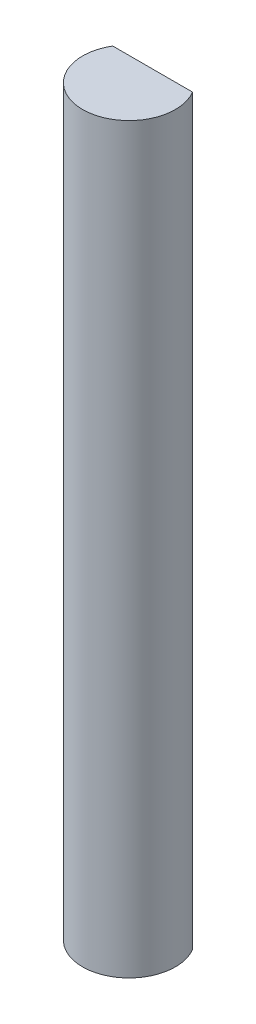
from build123d import *

# Parameters (mm, degrees)
BOSS_EXTRUDE1_DEPTH = 50.8


with BuildPart() as part:
    # Sketch1 → Boss-Extrude1 (new body)
    with BuildSketch(Plane(origin=(0, 0, 0), x_dir=(1, 0, 0), z_dir=(0, 1, 0))):
        with BuildLine():
            Line((2.730888358, 1.619528874), (-2.730888358, 1.619528874))
            ThreePointArc((-2.730888358, 1.619528874), (-0.839658997, -3.061959792), (3.175, 0))
            ThreePointArc((3.175, 0), (3.061959792, 0.839658997), (2.730888358, 1.619528874))
        make_face()
    extrude(amount=BOSS_EXTRUDE1_DEPTH)


solid = part.part
